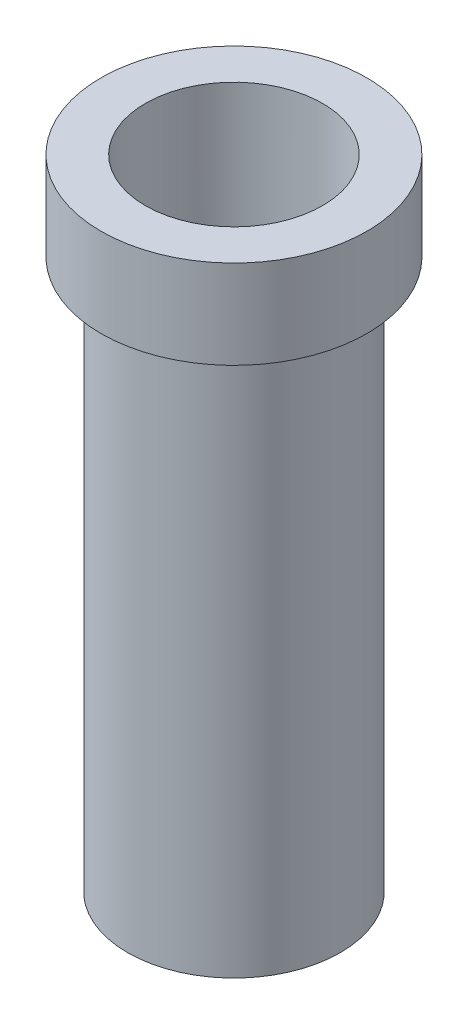
from build123d import *

# Parameters (mm, degrees)
ESQUISSE1_R      = 7.5
EXTRUSION1_DEPTH = 5
ESQUISSE2_R      = 6
EXTRUSION2_DEPTH = 31
EXTRUSION3_REACH = 38
ESQUISSE3_R      = 5


with BuildPart() as part:
    # Esquisse1 → Extrusion1 (new body)
    with BuildSketch(Plane(origin=(0, 0, 0), x_dir=(1, 0, 0), z_dir=(0, 1, 0))):
        Circle(ESQUISSE1_R)
    extrude(amount=EXTRUSION1_DEPTH)

    # Esquisse2 → Extrusion2 (add)
    with BuildSketch(Plane.XZ):
        Circle(ESQUISSE2_R)
    extrude(amount=EXTRUSION2_DEPTH)

    # Esquisse3 → Extrusion3 (cut, up to next)
    with BuildSketch(Plane(origin=(0, 5, 0), x_dir=(1, 0, 0), z_dir=(0, 1, 0)), mode=Mode.PRIVATE) as extrusion3_sk1:
        Circle(ESQUISSE3_R)
    extrusion3_tool1 = extrude(extrusion3_sk1.sketch, amount=-EXTRUSION3_REACH, mode=Mode.PRIVATE) & part.part
    add(extrusion3_tool1.solids().sort_by_distance((0, 5, 0))[0], mode=Mode.SUBTRACT)


solid = part.part
